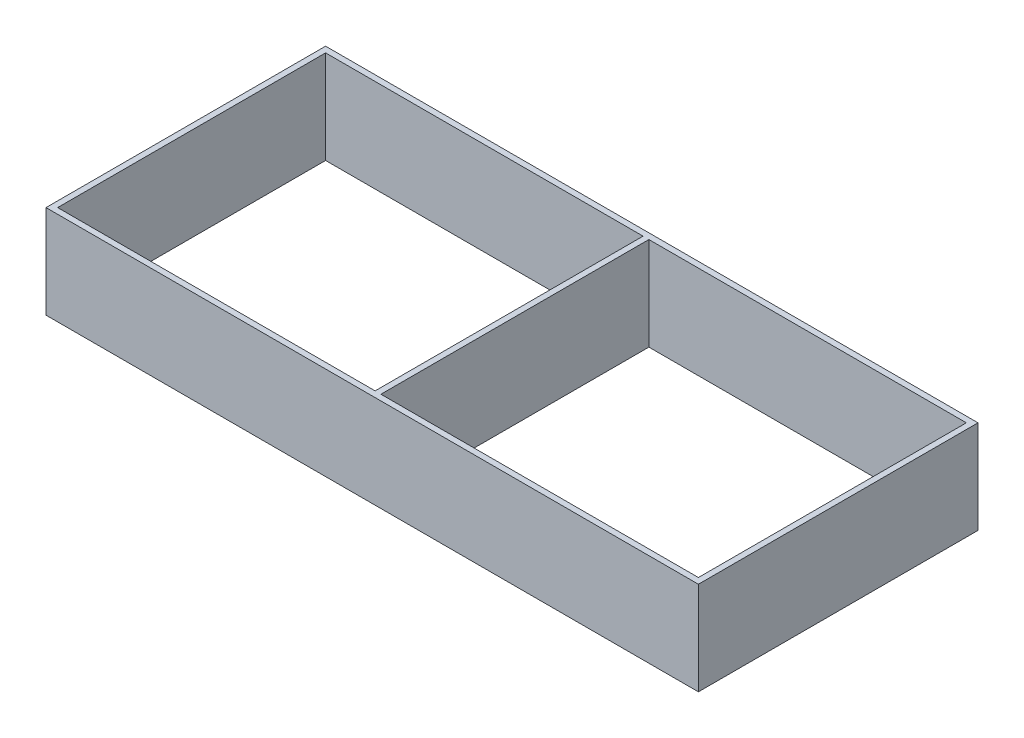
from build123d import *

# Parameters (mm, degrees)
SKETCH1_W           = 355.6
SKETCH1_H           = 152.4
SKETCH1_W_2         = 173.0375
SKETCH1_H_2         = 146.05
BOSS_EXTRUDE1_DEPTH = 50.8


with BuildPart() as part:
    # Sketch1 → Boss-Extrude1 (new body)
    with BuildSketch(Plane(origin=(0, 0, 0), x_dir=(1, 0, 0), z_dir=(0, 1, 0))):
        with Locations((-177.8, 76.2)):
            Rectangle(SKETCH1_W, SKETCH1_H)
        with Locations((-265.90625, 76.2)):
            Rectangle(SKETCH1_W_2, SKETCH1_H_2, mode=Mode.SUBTRACT)
        with Locations((-89.69375, 76.2)):
            Rectangle(SKETCH1_W_2, SKETCH1_H_2, mode=Mode.SUBTRACT)
    extrude(amount=BOSS_EXTRUDE1_DEPTH)


solid = part.part
